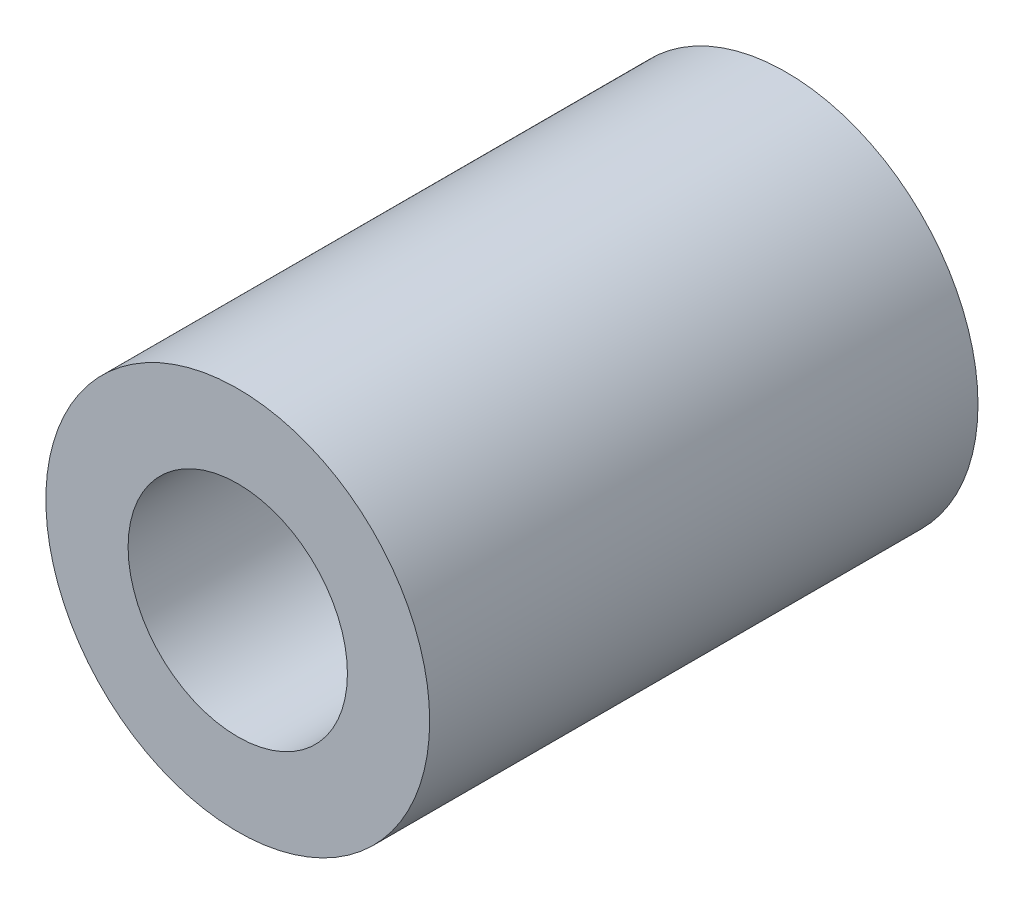
from build123d import *

# Parameters (mm, degrees)
SKETCH_1_R          = 7
SKETCH_1_R_2        = 3
EXTRUDE_1_DEPTH     = 10
SKETCH_2_R          = 7
EXTRUDE_2_DEPTH     = 10
SKETCH_3_R          = 4
CUT_EXTRUDE_1_DEPTH = 8


with BuildPart() as part:
    # 草图1 → 凸台-拉伸1 (new body)
    with BuildSketch(Plane.XY):
        Circle(SKETCH_1_R)
        Circle(SKETCH_1_R_2, mode=Mode.SUBTRACT)
    extrude(amount=EXTRUDE_1_DEPTH)

    # 草图2 → 凸台-拉伸2 (add)
    with BuildSketch(Plane.XY.offset(10)):
        Circle(SKETCH_2_R)
    extrude(amount=EXTRUDE_2_DEPTH)

    # 草图3 → 切除-拉伸1 (cut)
    with BuildSketch(Plane.XY.offset(20)):
        Circle(SKETCH_3_R)
    extrude(amount=-CUT_EXTRUDE_1_DEPTH, mode=Mode.SUBTRACT)


solid = part.part
